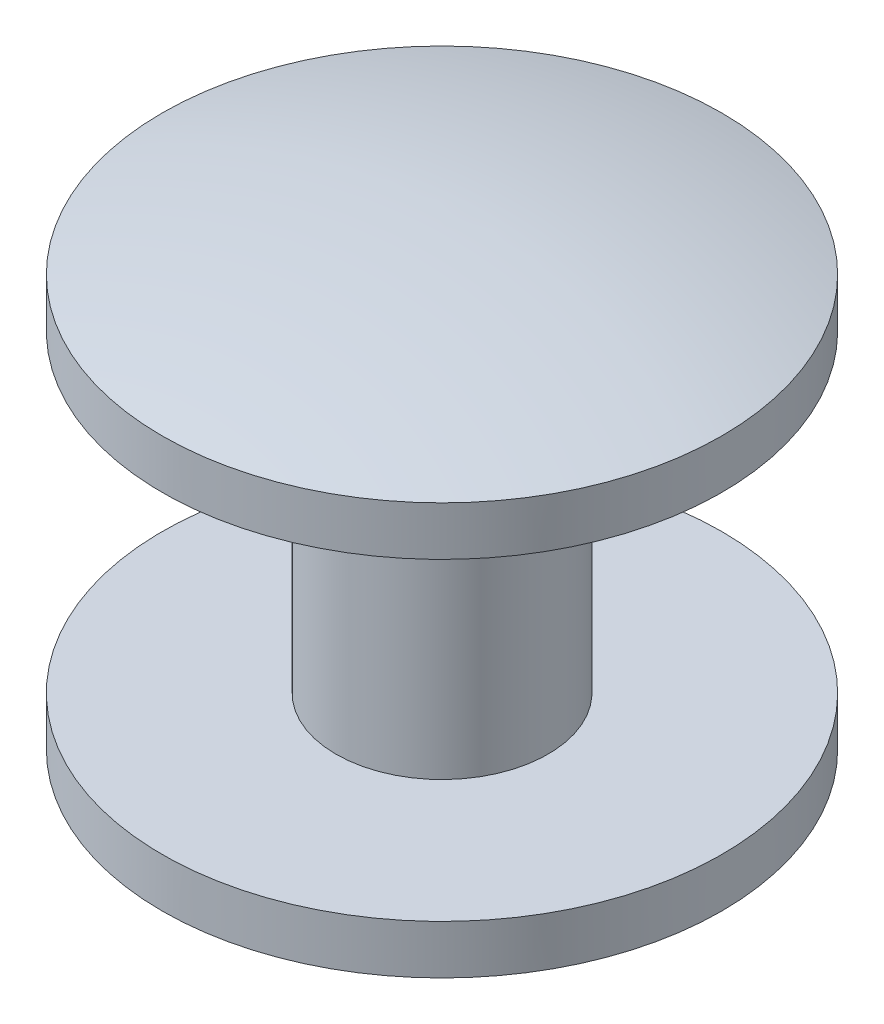
from build123d import *

# Parameters (mm, degrees)
SKETCH1_R           = 14.278677311
SKETCH1_R_2         = 5.411731441
BOSS_EXTRUDE1_DEPTH = 10.5
SKETCH1_3_R         = 14.278677311
SKETCH1_3_R_2       = 5.411731441
CUT_EXTRUDE1_DEPTH  = 8
DOME1_FACE_RADIUS   = 14.278677311
DOME1_HEIGHT        = 2
DOME2_FACE_RADIUS   = 14.278677311
DOME2_HEIGHT        = 2


with BuildPart() as part:
    # Sketch1 → Boss-Extrude1 (new, symmetric)
    with BuildSketch(Plane(origin=(0, 0, 0), x_dir=(1, 0, 0), z_dir=(0, 1, 0))):
        with Locations(Location((0, 0, 0), (0, 0, 90))):
            Circle(SKETCH1_R)
        Circle(SKETCH1_R_2, mode=Mode.SUBTRACT)
        Circle(SKETCH1_R_2)
    extrude(amount=BOSS_EXTRUDE1_DEPTH, both=True)

    # Sketch1_3 → Cut-Extrude1 (cut, symmetric)
    with BuildSketch(Plane(origin=(0, 0, 0), x_dir=(1, 0, 0), z_dir=(0, 1, 0))):
        with Locations(Location((0, 0, 0), (0, 0, 90))):
            Circle(SKETCH1_3_R)
        with Locations(Location((0, 0, 0), (0, 0, 270))):
            Circle(SKETCH1_3_R_2, mode=Mode.SUBTRACT)
    extrude(amount=CUT_EXTRUDE1_DEPTH, both=True, mode=Mode.SUBTRACT)

    # Dome1: a dome of height H over a round flat face of radius A is a cap of a sphere of radius (A * A + H * H) / (2 * H)
    dome1_r = (DOME1_FACE_RADIUS * DOME1_FACE_RADIUS + DOME1_HEIGHT * DOME1_HEIGHT) / (2 * DOME1_HEIGHT)
    dome1_base = Plane((0, -10.5, 0), z_dir=(0, -1, 0))
    with Locations(dome1_base.offset(DOME1_HEIGHT - dome1_r)):
        dome1_ball = Sphere(dome1_r, mode=Mode.PRIVATE)
    add(split(dome1_ball, bisect_by=dome1_base, keep=Keep.TOP, mode=Mode.PRIVATE))

    # Dome2: a dome of height H over a round flat face of radius A is a cap of a sphere of radius (A * A + H * H) / (2 * H)
    dome2_r = (DOME2_FACE_RADIUS * DOME2_FACE_RADIUS + DOME2_HEIGHT * DOME2_HEIGHT) / (2 * DOME2_HEIGHT)
    dome2_base = Plane((0, 10.5, 0), z_dir=(0, 1, 0))
    with Locations(dome2_base.offset(DOME2_HEIGHT - dome2_r)):
        dome2_ball = Sphere(dome2_r, mode=Mode.PRIVATE)
    add(split(dome2_ball, bisect_by=dome2_base, keep=Keep.TOP, mode=Mode.PRIVATE))


solid = part.part
